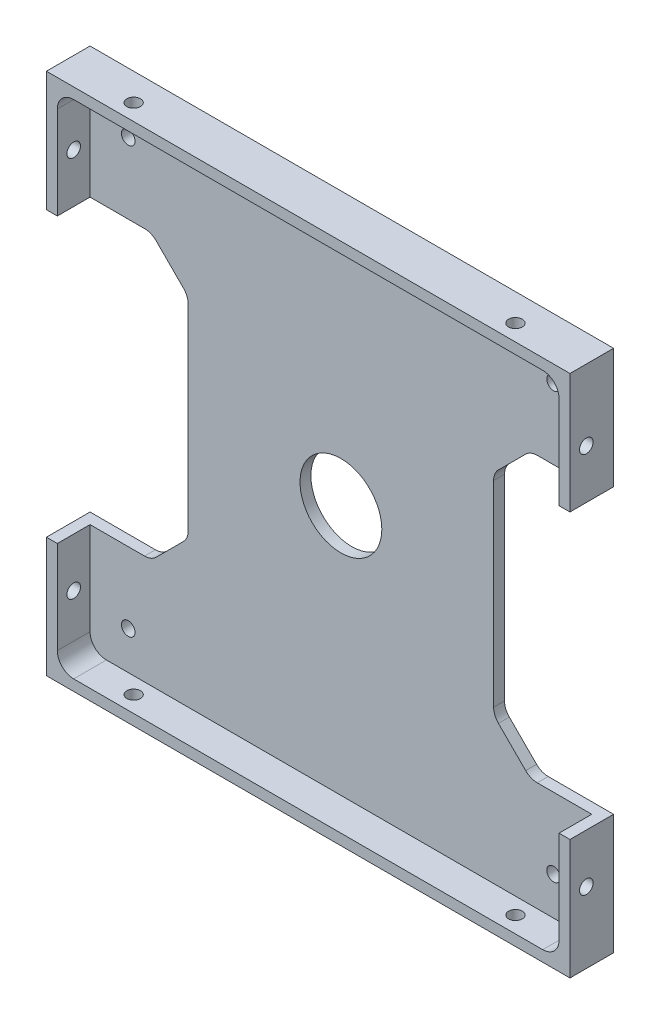
from build123d import *

# Parameters (mm, degrees)
SKETCH1_W                      = 96
SKETCH1_H                      = 96
BOSS_EXTRUDE1_DEPTH            = 8
SKETCH2_W                      = 92
SKETCH2_H                      = 92
COMPONENT_PLATFORM_DEPTH       = 6
CABLE_SLOTS_DEPTH              = 6
SKETCH4_R                      = 7.5
CENTER_MASS_CUT_DEPTH          = 6
INNER_CORNER_FILLETS_R         = 3
M3X0_5_TAPPED_HOLE1_AT_2_COUNT = 2
M3X0_5_TAPPED_HOLE1_AT_2_PITCH = 70
M3X0_5_TAPPED_HOLE2_AT_2_COUNT = 2
M3X0_5_TAPPED_HOLE2_AT_2_PITCH = 70
M3X0_5_TAPPED_HOLE3_D          = 2.5
M3X0_5_TAPPED_HOLE3_DEPTH      = 10
M3X0_5_TAPPED_HOLE3_TIP        = 0.751075774


with BuildPart() as part:
    # Sketch1 → Boss-Extrude1 (new body)
    with BuildSketch(Plane.XY):
        Rectangle(SKETCH1_W, SKETCH1_H)
    extrude(amount=BOSS_EXTRUDE1_DEPTH)

    # Sketch2 → Component Platform (cut)
    with BuildSketch(Plane.XY.offset(8)):
        Rectangle(SKETCH2_W, SKETCH2_H)
    extrude(amount=-COMPONENT_PLATFORM_DEPTH, mode=Mode.SUBTRACT)

    # Sketch3 → Cable Slots (cut, symmetric)
    with BuildSketch(Plane.XY.offset(2)):
        with BuildLine():
            Line((-33.878679656, -25.121320344), (-28.878679656, -20.121320344))
            ThreePointArc((-28.878679656, -20.121320344), (-28.228361402, -19.148050297), (-28, -18))
            Line((-28, -18), (-28, 18))
            ThreePointArc((-28, 18), (-28.228361402, 19.148050297), (-28.878679656, 20.121320344))
            Line((-28.878679656, 20.121320344), (-33.878679656, 25.121320344))
            ThreePointArc((-33.878679656, 25.121320344), (-34.851949703, 25.771638598), (-36, 26))
            Line((-36, 26), (-48, 26))
            Line((-48, 26), (-48, -26))
            Line((-48, -26), (-36, -26))
            ThreePointArc((-36, -26), (-34.851949703, -25.771638598), (-33.878679656, -25.121320344))
        make_face()
        with BuildLine():
            Line((48, -26), (48, 26))
            Line((48, 26), (36, 26))
            ThreePointArc((36, 26), (34.851949703, 25.771638598), (33.878679656, 25.121320344))
            Line((33.878679656, 25.121320344), (28.878679656, 20.121320344))
            ThreePointArc((28.878679656, 20.121320344), (28.228361402, 19.148050297), (28, 18))
            Line((28, 18), (28, -18))
            ThreePointArc((28, -18), (28.228361402, -19.148050297), (28.878679656, -20.121320344))
            Line((28.878679656, -20.121320344), (33.878679656, -25.121320344))
            ThreePointArc((33.878679656, -25.121320344), (34.851949703, -25.771638598), (36, -26))
            Line((36, -26), (48, -26))
        make_face()
    extrude(amount=CABLE_SLOTS_DEPTH, both=True, mode=Mode.SUBTRACT)

    # Sketch4 → Center Mass Cut (cut)
    with BuildSketch(Plane.XY.offset(2)):
        Circle(SKETCH4_R)
    extrude(amount=-CENTER_MASS_CUT_DEPTH, mode=Mode.SUBTRACT)

    # Inner Corner Fillets
    inner_corner_fillets_edges = [part.edges().sort_by_distance(p)[0] for p in [
        (-46, -46, 5),
        (-46, 46, 5),
        (46, 46, 5),
        (46, -46, 5),
    ]]
    fillet(inner_corner_fillets_edges, radius=INNER_CORNER_FILLETS_R)

    # Sketch11 → M3x0.5 Tapped Hole1 (revolve, cut)
    with BuildSketch(Plane(origin=(-35, -48, 5), x_dir=(0, 0, -1), z_dir=(1, 0, 0))):
        Polygon((0, 0), (0, 10.751075774), (1.25, 10), (1.25, 0), align=None)
    m3x0_5_tapped_hole1 = revolve(axis=Axis((-35, -54.35, 5), (0, 1, 0)), mode=Mode.SUBTRACT)

    # M3x0.5 Tapped Hole1 at 2: M3x0.5 Tapped Hole1 ×2
    with Locations(*[(i * M3X0_5_TAPPED_HOLE1_AT_2_PITCH, 0, 0) for i in range(1, M3X0_5_TAPPED_HOLE1_AT_2_COUNT)]):
        add(m3x0_5_tapped_hole1, mode=Mode.SUBTRACT)

    # Sketch13 → M3x0.5 Tapped Hole2 (revolve, cut)
    with BuildSketch(Plane(origin=(48, -35, 5), x_dir=(0, 0, -1), z_dir=(0, 1, 0))):
        Polygon((0, 0), (0, 10.751075774), (1.25, 10), (1.25, 0), align=None)
    m3x0_5_tapped_hole2 = revolve(axis=Axis((54.35, -35, 5), (-1, 0, 0)), mode=Mode.SUBTRACT)

    # M3x0.5 Tapped Hole2 at 2: M3x0.5 Tapped Hole2 ×2
    with Locations(*[(0, i * M3X0_5_TAPPED_HOLE2_AT_2_PITCH, 0) for i in range(1, M3X0_5_TAPPED_HOLE2_AT_2_COUNT)]):
        add(m3x0_5_tapped_hole2, mode=Mode.SUBTRACT)

    # Mirror1: M3x0.5 Tapped Hole1 across plane
    add(m3x0_5_tapped_hole1.mirror(Plane(origin=(0, 0, 0), x_dir=(0, 0, 1), z_dir=(0, -1, 0))), mode=Mode.SUBTRACT)

    # Mirror1 copy 1 sketch → Mirror1 copy 1 (revolve, cut)
    with BuildSketch(Plane(origin=(35, 48, 5), x_dir=(0, 0, -1), z_dir=(1, 0, 0))):
        Polygon((0, 0), (0, -10.751075774), (1.25, -10), (1.25, 0), align=None)
    revolve(axis=Axis((35, 54.35, 5), (0, 1, 0)), mode=Mode.SUBTRACT)

    # Mirror2: M3x0.5 Tapped Hole2 across plane
    add(m3x0_5_tapped_hole2.mirror(Plane(origin=(0, 0, 0), x_dir=(0, 0, 1), z_dir=(1, 0, 0))), mode=Mode.SUBTRACT)

    # Mirror2 copy 1 sketch → Mirror2 copy 1 (revolve, cut)
    with BuildSketch(Plane(origin=(-48, 35, 5), x_dir=(0, 0, -1), z_dir=(0, 1, 0))):
        Polygon((0, 0), (0, -10.751075774), (1.25, -10), (1.25, 0), align=None)
    revolve(axis=Axis((-54.35, 35, 5), (-1, 0, 0)), mode=Mode.SUBTRACT)

    # M3x0.5 Tapped Hole3
    with Locations(Plane.XY.offset(2)):
        with Locations((-39, -39), (39, -39), (39, 39), (-39, 39)):
            Hole(M3X0_5_TAPPED_HOLE3_D / 2, depth=M3X0_5_TAPPED_HOLE3_DEPTH)
            with Locations((0, 0, -(M3X0_5_TAPPED_HOLE3_DEPTH + M3X0_5_TAPPED_HOLE3_TIP / 2))):  # 118° drill point
                Cone(0, M3X0_5_TAPPED_HOLE3_D / 2, M3X0_5_TAPPED_HOLE3_TIP, mode=Mode.SUBTRACT)


solid = part.part
